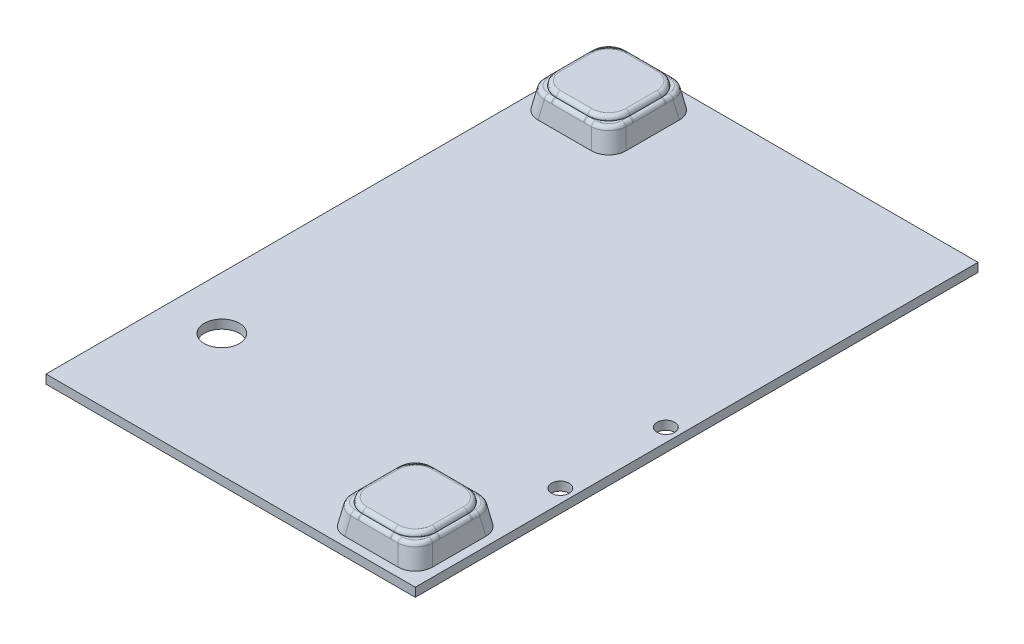
from build123d import *

# Parameters (mm, degrees)
SKETCH1_W                     = 159.000776249
SKETCH1_H                     = 337.554266017
BOSS_EXTRUDE1_DEPTH           = 6.35
SKETCH2_W                     = 266.7
SKETCH2_H                     = 406.4
BOSS_EXTRUDE2_DEPTH           = 6.35
SKETCH3_R                     = 12.7
CUT_EXTRUDE1_DEPTH            = 10
SKETCH4_R                     = 6.35
CUT_EXTRUDE2_DEPTH            = 12.7
SKETCH5_W                     = 63.5
SKETCH5_H                     = 63.5
BOSS_EXTRUDE3_DEPTH           = 15.24
BOSS_EXTRUDE3_DRAFT           = 10
BOSS_EXTRUDE3_PROFILE_2_DEPTH = 15.24
BOSS_EXTRUDE3_PROFILE_2_DRAFT = 10
SKETCH6_W                     = 53.045553629
SKETCH6_H                     = 53.045553628
BOSS_EXTRUDE4_DEPTH           = 3.048
BOSS_EXTRUDE4_DRAFT           = 5
BOSS_EXTRUDE4_PROFILE_2_DEPTH = 3.048
BOSS_EXTRUDE4_PROFILE_2_DRAFT = 5
FILLET1_R                     = 15.24
FILLET2_R                     = 12.7
FILLET3_R                     = 3.048
FILLET4_R                     = 3.048


with BuildPart() as part:
    # Sketch1 → Boss-Extrude1 (new body)
    with BuildSketch(Plane(origin=(0, 0, 0), x_dir=(1, 0, 0), z_dir=(0, 1, 0))):
        with Locations((1.325, -61.276263003)):
            Rectangle(SKETCH1_W, SKETCH1_H)
    extrude(amount=BOSS_EXTRUDE1_DEPTH)

    # Sketch2 → Boss-Extrude2 (add)
    with BuildSketch(Plane(origin=(0, 6.35, 0), x_dir=(1, 0, 0), z_dir=(0, 1, 0))):
        with Locations((1.325, -61.276263004)):
            Rectangle(SKETCH2_W, SKETCH2_H)
    extrude(amount=-BOSS_EXTRUDE2_DEPTH)

    # Sketch3 → Cut-Extrude1 (cut)
    with BuildSketch(Plane(origin=(0, 6.35, 0), x_dir=(1, 0, 0), z_dir=(0, 1, 0))):
        with Locations(Location((-93.925, -175.576263004, 0), (0, 0, 270))):
            Circle(SKETCH3_R)
    extrude(amount=-CUT_EXTRUDE1_DEPTH, mode=Mode.SUBTRACT)

    # Sketch4 → Cut-Extrude2 (cut)
    with BuildSketch(Plane(origin=(0, 6.35, 0), x_dir=(1, 0, 0), z_dir=(0, 1, 0))):
        with Locations(Location((125.15, -150.176263004, 0), (0, 0, 270))):
            Circle(SKETCH4_R)
        with Locations(Location((125.15, -73.976263004, 0), (0, 0, 270))):
            Circle(SKETCH4_R)
    extrude(amount=-CUT_EXTRUDE2_DEPTH, mode=Mode.SUBTRACT)


with BuildPart() as boss_extrude3_tool:
    # Sketch5 → Boss-Extrude3 (with draft: the straight prism first)
    with BuildSketch(Plane(origin=(0, 6.35, 0), x_dir=(1, 0, 0), z_dir=(0, 1, 0))):
        with Locations((96.575, -226.376263004)):
            Rectangle(SKETCH5_W, SKETCH5_H)
    extrude(amount=BOSS_EXTRUDE3_DEPTH)
    # Boss-Extrude3: the draft: its side faces are tilted about the plane it starts from
    boss_extrude3_sides = [boss_extrude3_tool.faces().sort_by_distance(p)[0] for p in [
        (128.325, 13.97, 226.376263004),
        (96.575, 13.97, 194.626263004),
        (64.825, 13.97, 226.376263004),
        (96.575, 13.97, 258.126263004),
    ]]
    draft(boss_extrude3_sides, Plane(origin=(0, 6.35, 0), x_dir=(1, 0, 0), z_dir=(0, 1, 0)), BOSS_EXTRUDE3_DRAFT)


with BuildPart() as part_1:
    add(part.part)

    # Boss-Extrude3: add boss_extrude3_tool
    add(boss_extrude3_tool.part)


with BuildPart() as boss_extrude3_profile_2_tool:
    # Sketch5 → Boss-Extrude3 profile 2 (with draft: the straight prism first)
    with BuildSketch(Plane(origin=(0, 6.35, 0), x_dir=(1, 0, 0), z_dir=(0, 1, 0))):
        with Locations((-93.925, 103.823736996)):
            Rectangle(SKETCH5_W, SKETCH5_H)
    extrude(amount=BOSS_EXTRUDE3_PROFILE_2_DEPTH)
    # Boss-Extrude3 profile 2: the draft: its side faces are tilted about the plane it starts from
    boss_extrude3_profile_2_sides = [boss_extrude3_profile_2_tool.faces().sort_by_distance(p)[0] for p in [
        (-62.175, 13.97, -103.823736996),
        (-93.925, 13.97, -135.573736996),
        (-125.675, 13.97, -103.823736996),
        (-93.925, 13.97, -72.073736996),
    ]]
    draft(boss_extrude3_profile_2_sides, Plane(origin=(0, 6.35, 0), x_dir=(1, 0, 0), z_dir=(0, 1, 0)), BOSS_EXTRUDE3_PROFILE_2_DRAFT)


with BuildPart() as part_2:
    add(part_1.part)

    # Boss-Extrude3 profile 2: add boss_extrude3_profile_2_tool
    add(boss_extrude3_profile_2_tool.part)


with BuildPart() as boss_extrude4_tool:
    # Sketch6 → Boss-Extrude4 (with draft: the straight prism first)
    with BuildSketch(Plane(origin=(0, 21.59, 0), x_dir=(1, 0, 0), z_dir=(0, 1, 0))):
        with Locations((-93.925000001, 103.823736996)):
            Rectangle(SKETCH6_W, SKETCH6_H)
    extrude(amount=BOSS_EXTRUDE4_DEPTH)
    # Boss-Extrude4: the draft: its side faces are tilted about the plane it starts from
    boss_extrude4_sides = [boss_extrude4_tool.faces().sort_by_distance(p)[0] for p in [
        (-67.402223186, 23.114, -103.823736996),
        (-93.925, 23.114, -130.34651381),
        (-120.447776815, 23.114, -103.823736996),
        (-93.925, 23.114, -77.300960182),
    ]]
    draft(boss_extrude4_sides, Plane(origin=(0, 21.59, 0), x_dir=(1, 0, 0), z_dir=(0, 1, 0)), BOSS_EXTRUDE4_DRAFT)


with BuildPart() as part_3:
    add(part_2.part)

    # Boss-Extrude4: add boss_extrude4_tool
    add(boss_extrude4_tool.part)


with BuildPart() as boss_extrude4_profile_2_tool:
    # Sketch6 → Boss-Extrude4 profile 2 (with draft: the straight prism first)
    with BuildSketch(Plane(origin=(0, 21.59, 0), x_dir=(1, 0, 0), z_dir=(0, 1, 0))):
        with Locations((96.575, -226.376263004)):
            Rectangle(SKETCH6_W, SKETCH6_H)
    extrude(amount=BOSS_EXTRUDE4_PROFILE_2_DEPTH)
    # Boss-Extrude4 profile 2: the draft: its side faces are tilted about the plane it starts from
    boss_extrude4_profile_2_sides = [boss_extrude4_profile_2_tool.faces().sort_by_distance(p)[0] for p in [
        (123.097776814, 23.114, 226.376263004),
        (96.575, 23.114, 199.85348619),
        (70.052223185, 23.114, 226.376263004),
        (96.575, 23.114, 252.899039818),
    ]]
    draft(boss_extrude4_profile_2_sides, Plane(origin=(0, 21.59, 0), x_dir=(1, 0, 0), z_dir=(0, 1, 0)), BOSS_EXTRUDE4_PROFILE_2_DRAFT)


with BuildPart() as part_4:
    add(part_3.part)

    # Boss-Extrude4 profile 2: add boss_extrude4_profile_2_tool
    add(boss_extrude4_profile_2_tool.part)

    # Fillet1
    fillet1_edges = [part_4.edges().sort_by_distance(p)[0] for p in [
        (-120.314444091, 23.114, -130.213181087),
        (-120.314444091, 23.114, -77.434292905),
        (-67.53555591, 23.114, -77.434292905),
        (-67.53555591, 23.114, -130.213181087),
        (70.185555909, 23.114, 199.986818913),
        (70.185555909, 23.114, 252.765707095),
        (122.96444409, 23.114, 252.765707095),
        (122.96444409, 23.114, 199.986818913),
    ]]
    fillet(fillet1_edges, radius=FILLET1_R)

    # Fillet2
    fillet2_edges = [part_4.edges().sort_by_distance(p)[0] for p in [
        (66.168611592, 13.97, 195.969874597),
        (66.168611592, 13.97, 256.782651411),
        (126.981388407, 13.97, 256.782651411),
        (126.981388407, 13.97, 195.969874597),
        (-124.331388408, 13.97, -134.230125403),
        (-124.331388408, 13.97, -73.417348589),
        (-63.518611593, 13.97, -73.417348589),
        (-63.518611593, 13.97, -134.230125403),
    ]]
    fillet(fillet2_edges, radius=FILLET2_R)

    # Fillet3
    fillet3_edges = [part_4.edges().sort_by_distance(p)[0] for p in [
        (-93.925, 21.59, -132.88651381),
        (-64.862223186, 21.59, -103.823736996),
        (-122.987776815, 21.59, -103.823736996),
        (-93.925, 21.59, -74.760960182),
        (-119.347111423, 21.59, -129.245848419),
        (-119.347111423, 21.59, -78.401625574),
        (-68.502888578, 21.59, -78.401625574),
        (-68.502888578, 21.59, -129.245848419),
        (67.512223185, 21.59, 226.376263004),
        (96.575, 21.59, 197.31348619),
        (96.575, 21.59, 255.439039818),
        (125.637776814, 21.59, 226.376263004),
        (71.152888577, 21.59, 251.798374426),
        (121.997111422, 21.59, 251.798374426),
        (121.997111422, 21.59, 200.954151581),
        (71.152888577, 21.59, 200.954151581),
    ]]
    fillet(fillet3_edges, radius=FILLET3_R)

    # Fillet4
    fillet4_edges = [part_4.edges().sort_by_distance(p)[0] for p in [
        (96.575, 24.638, 200.120151636),
        (122.831111367, 24.638, 226.376263004),
        (70.318888632, 24.638, 226.376263004),
        (96.575, 24.638, 252.632374371),
        (74.758624172, 24.638, 248.192638831),
        (118.391375827, 24.638, 248.192638831),
        (74.758624172, 24.638, 204.559887176),
        (118.391375827, 24.638, 204.559887176),
        (-67.668888633, 24.638, -103.823736996),
        (-93.925, 24.638, -77.567625629),
        (-120.181111368, 24.638, -103.823736996),
        (-93.925, 24.638, -130.079848364),
        (-115.741375828, 24.638, -125.640112824),
        (-72.108624173, 24.638, -125.640112824),
        (-115.741375828, 24.638, -82.007361169),
        (-72.108624173, 24.638, -82.007361169),
    ]]
    fillet(fillet4_edges, radius=FILLET4_R)


solid = part_4.part
